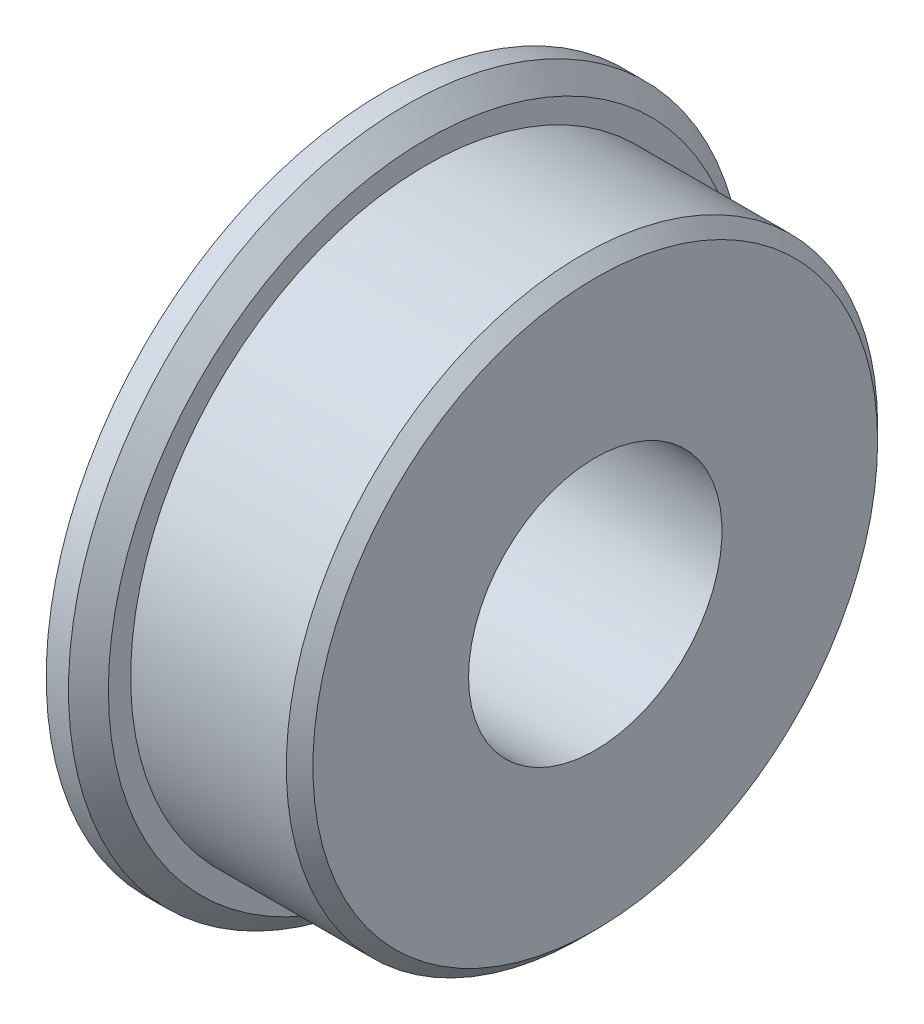
from build123d import *

# Parameters (mm, degrees)
SKETCH1_R           = 25.4
BOSS_EXTRUDE1_DEPTH = 3.175
SKETCH2_R           = 22.225
BOSS_EXTRUDE2_DEPTH = 12.7
SKETCH3_R           = 9.525
CUT_EXTRUDE1_DEPTH  = 16.875
CHAMFER1_SIZE       = 1.5
CHAMFER2_SIZE       = 1


with BuildPart() as part:
    # Sketch1 → Boss-Extrude1 (new body)
    with BuildSketch(Plane(origin=(0, 0, 0), x_dir=(0, 0, -1), z_dir=(1, 0, 0))):
        Circle(SKETCH1_R)
    extrude(amount=BOSS_EXTRUDE1_DEPTH)

    # Sketch2 → Boss-Extrude2 (add)
    with BuildSketch(Plane(origin=(3.175, 0, 0), x_dir=(0, 0, -1), z_dir=(1, 0, 0))):
        Circle(SKETCH2_R)
    extrude(amount=BOSS_EXTRUDE2_DEPTH)

    # Sketch3 → Cut-Extrude1 (cut, through all)
    with BuildSketch(Plane.ZY):
        Circle(SKETCH3_R)
    extrude(amount=-CUT_EXTRUDE1_DEPTH, mode=Mode.SUBTRACT)

    # Chamfer1
    chamfer1_edges = [part.edges().sort_by_distance(p)[0] for p in [
        (3.175, 0, 25.4),
    ]]
    chamfer(chamfer1_edges, length=CHAMFER1_SIZE)

    # Chamfer2
    chamfer2_edges = [part.edges().sort_by_distance(p)[0] for p in [
        (15.875, 0, 22.225),
    ]]
    chamfer(chamfer2_edges, length=CHAMFER2_SIZE)


solid = part.part
